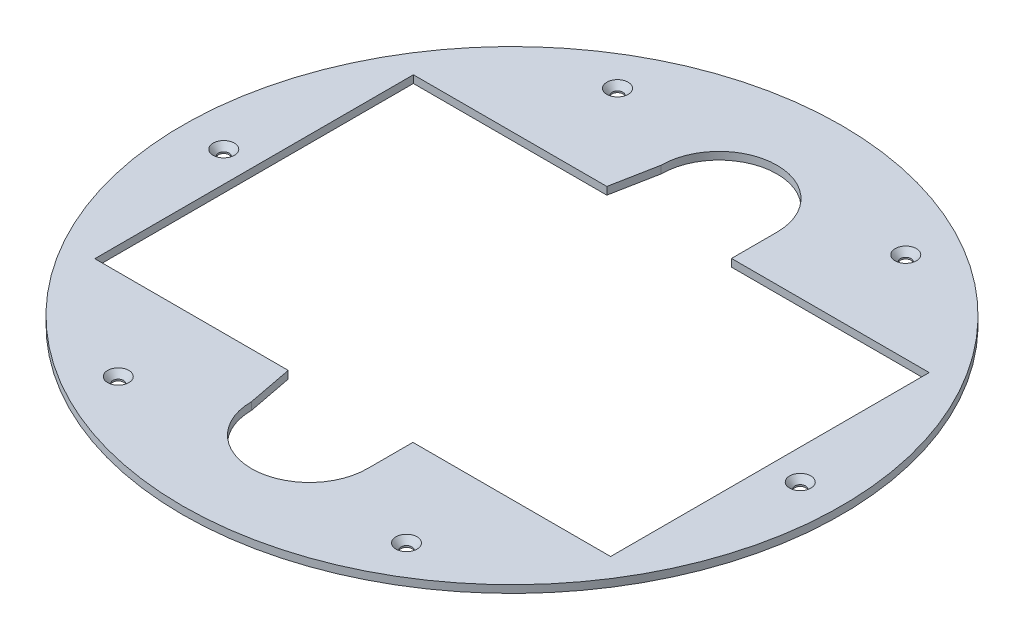
from build123d import *

# Parameters (mm, degrees)
SKETCH1_R         = 137.941576563
EXTRUDE1_DEPTH    = 3.175
EXTRUDE3_DEPTH    = 4.175
SKETCH4_R         = 1.5875
EXTRUDE4_DEPTH    = 4.175
CIRPATTERN1_COUNT = 6


with BuildPart() as part:
    # Sketch1 → Extrude1 (new body)
    with BuildSketch(Plane(origin=(0, 0, 0), x_dir=(1, 0, 0), z_dir=(0, 1, 0))):
        with Locations(Location((0, 0, 0), (0, 0, 270))):  # turned: the seam where the file's is
            Circle(SKETCH1_R)
    extrude(amount=EXTRUDE1_DEPTH)

    # Sketch3 → Extrude3 (cut, through all)
    with BuildSketch(Plane(origin=(0, 3.175, 0), x_dir=(1, 0, 0), z_dir=(0, 1, 0))):
        with BuildLine():
            Line((25.204878031, -66.675), (107.95, -66.675))
            Line((107.95, -66.675), (107.95, 66.675))
            Line((107.95, 66.675), (25.204878031, 66.675))
            Line((25.204878031, 66.675), (25.204878031, 85.725))
            ThreePointArc((25.204878031, 85.725), (0.937561054, 109.992316976), (-23.329755922, 85.725))
            Line((-23.329755922, 85.725), (-26.9875, 66.675))
            Line((-26.9875, 66.675), (-107.95, 66.675))
            Line((-107.95, 66.675), (-107.95, -66.675))
            Line((-107.95, -66.675), (-26.9875, -66.675))
            Line((-26.9875, -66.675), (-23.329755922, -85.725))
            ThreePointArc((-23.329755922, -85.725), (0.937561054, -109.992316976), (25.204878031, -85.725))
            Line((25.204878031, -85.725), (25.204878031, -66.675))
        make_face()
    extrude(amount=-EXTRUDE3_DEPTH, mode=Mode.SUBTRACT)

    # Sketch4 → Extrude4 (cut, through all)
    with BuildSketch(Plane(origin=(0, 3.175, 0), x_dir=(-1, 0, 0), z_dir=(0, 1, 0))):
        with Locations(Location((120.65, 0, 0), (0, 0, 90))):  # turned: the seam where the file's is
            Circle(SKETCH4_R)
    extrude(amount=-EXTRUDE4_DEPTH, mode=Mode.SUBTRACT)

    # Sketch5 → CSK for #8 Flat Head Socket Cap Screw1 (revolve, cut)
    with BuildSketch(Plane(origin=(-120.65, 3.175, 0), x_dir=(0, 0, 1), z_dir=(1, 0, 0))):
        Polygon((0, 0), (0, 3.175), (2.2479, 3.175), (2.2479, 2.527474428), (4.445, 0), align=None)
    csk_for_8_flat_head_socket_cap_screw1 = revolve(axis=Axis((-120.65, 9.525, 0), (0, -1, 0)), mode=Mode.SUBTRACT)

    # CirPattern1: CSK for #8 Flat Head Socket Cap Screw1 ×6 about axis
    cirpattern1_axis = Axis((0, 0, 0), (0, 1, 0))
    for i in range(1, CIRPATTERN1_COUNT):
        add(csk_for_8_flat_head_socket_cap_screw1.rotate(cirpattern1_axis, i * 360 / CIRPATTERN1_COUNT), mode=Mode.SUBTRACT)


solid = part.part
